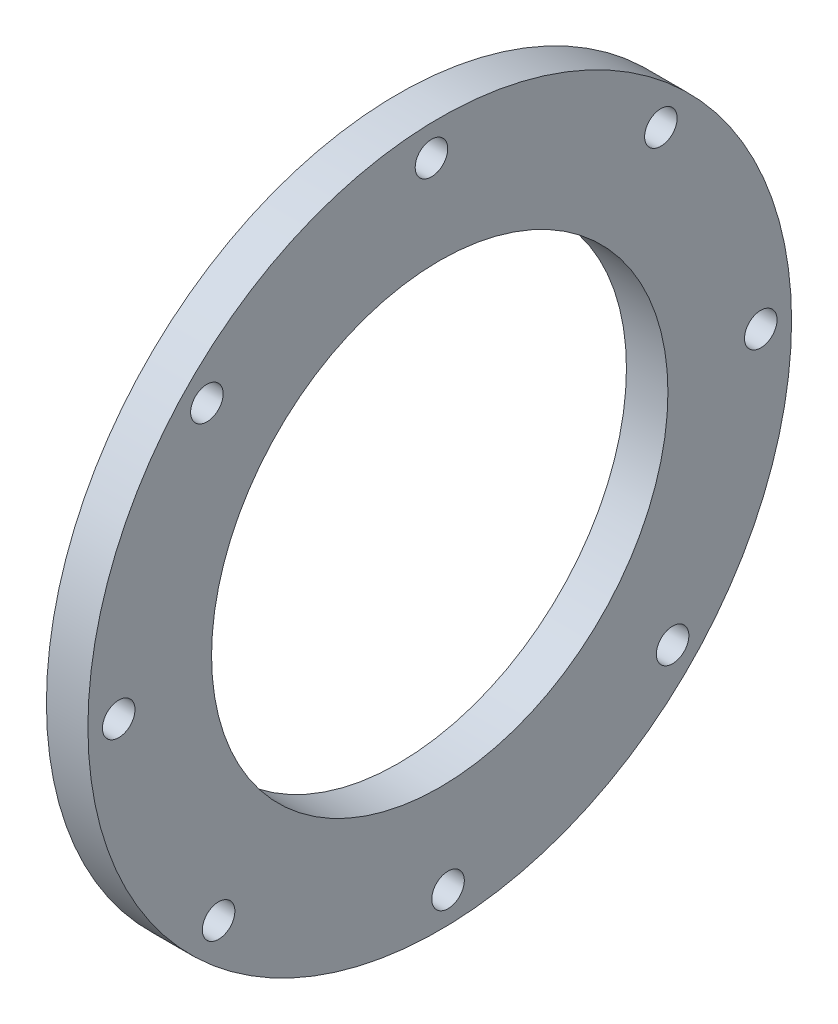
from build123d import *

# Parameters (mm, degrees)
SKETCH1_R           = 53.848
SKETCH1_R_2         = 34.925
SKETCH1_R_3         = 2.4892
BOSS_EXTRUDE1_DEPTH = 6.35


with BuildPart() as part:
    # Sketch1 → Boss-Extrude1 (new body)
    with BuildSketch(Plane.ZY.offset(88.9)):
        Circle(SKETCH1_R)
        Circle(SKETCH1_R_2, mode=Mode.SUBTRACT)
        with Locations((-33.845113149, 35.638918571)):
            Circle(SKETCH1_R_3, mode=Mode.SUBTRACT)
        with Locations((1.268411978, 49.132630014)):
            Circle(SKETCH1_R_3, mode=Mode.SUBTRACT)
        with Locations((35.638918571, 33.845113149)):
            Circle(SKETCH1_R_3, mode=Mode.SUBTRACT)
        with Locations((49.132630014, -1.268411978)):
            Circle(SKETCH1_R_3, mode=Mode.SUBTRACT)
        with Locations((33.845113149, -35.638918571)):
            Circle(SKETCH1_R_3, mode=Mode.SUBTRACT)
        with Locations((-1.268411978, -49.132630014)):
            Circle(SKETCH1_R_3, mode=Mode.SUBTRACT)
        with Locations((-35.638918571, -33.845113149)):
            Circle(SKETCH1_R_3, mode=Mode.SUBTRACT)
        with Locations((-49.132630014, 1.268411978)):
            Circle(SKETCH1_R_3, mode=Mode.SUBTRACT)
    extrude(amount=BOSS_EXTRUDE1_DEPTH)


solid = part.part
